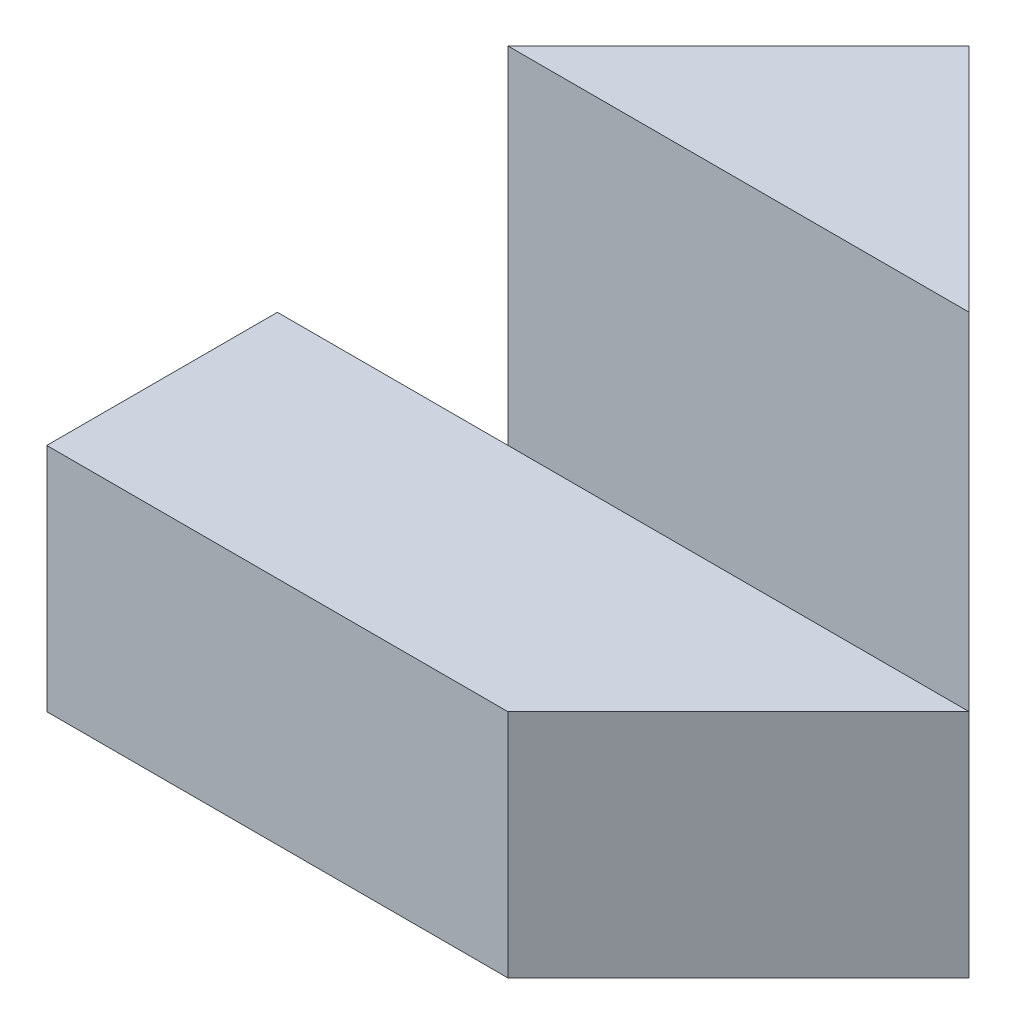
from build123d import *

# Parameters (mm, degrees)
SKETCH1_W           = 4
SKETCH1_H           = 5
BOSS_EXTRUDE1_DEPTH = 2
SKETCH2_W           = 4
SKETCH2_H           = 2
BOSS_EXTRUDE2_DEPTH = 2
BOSS_EXTRUDE3_DEPTH = 2
BOSS_EXTRUDE4_DEPTH = 5
CUT_EXTRUDE1_DEPTH  = 5


with BuildPart() as part:
    # Sketch1 → Boss-Extrude1 (new body)
    with BuildSketch(Plane.XY):
        Rectangle(SKETCH1_W, SKETCH1_H)
    extrude(amount=BOSS_EXTRUDE1_DEPTH)

    # Sketch2 → Boss-Extrude2 (add)
    with BuildSketch(Plane.XY.offset(2)):
        with Locations((0, -1.5)):
            Rectangle(SKETCH2_W, SKETCH2_H)
    extrude(amount=BOSS_EXTRUDE2_DEPTH)

    # Sketch3 → Boss-Extrude3 (add)
    with BuildSketch(Plane(origin=(0, -0.5, 0), x_dir=(1, 0, 0), z_dir=(0, 1, 0))):
        Polygon((2, -4), (4, -2), (2, -2), align=None)
    extrude(amount=-BOSS_EXTRUDE3_DEPTH)

    # Sketch4 → Boss-Extrude4 (add)
    with BuildSketch(Plane(origin=(0, 2.5, 0), x_dir=(1, 0, 0), z_dir=(0, 1, 0))):
        Polygon((2, 0), (4, -2), (1.353311903, -2), align=None)
    extrude(amount=-BOSS_EXTRUDE4_DEPTH)

    # Sketch5 → Cut-Extrude1 (cut)
    with BuildSketch(Plane(origin=(0, 2.5, 0), x_dir=(1, 0, 0), z_dir=(0, 1, 0))):
        Polygon((-2, -2), (0, -2), (2, 0), (-2, 0), align=None)
    extrude(amount=-CUT_EXTRUDE1_DEPTH, mode=Mode.SUBTRACT)


solid = part.part
